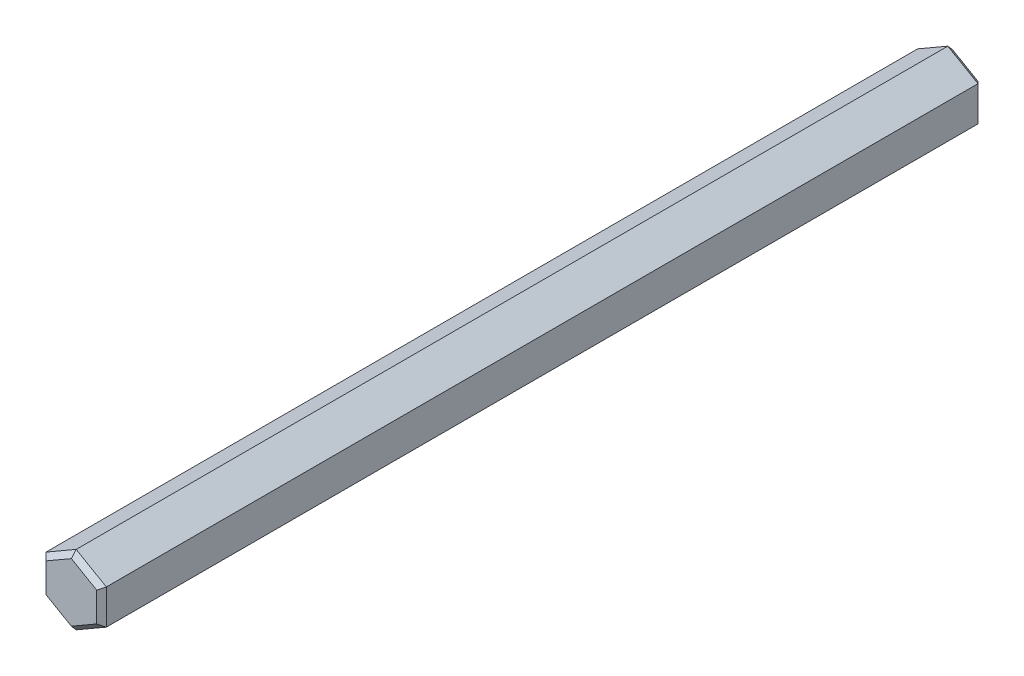
from build123d import *

# Parameters (mm, degrees)
BOSS_EXTRUDE1_DEPTH = 73.025
CHAMFER1_SIZE       = 0.4


with BuildPart() as part:
    # Sketch1 → Boss-Extrude1 (new body)
    with BuildSketch(Plane.XY.offset(75)):
        Polygon((0, -2.886751346), (2.5, -1.443375673), (2.5, 1.443375673), (0, 2.886751346), (-2.5, 1.443375673), (-2.5, -1.443375673), align=None)
    extrude(amount=-BOSS_EXTRUDE1_DEPTH)

    # Chamfer1
    chamfer1_edges = [part.edges().sort_by_distance(p)[0] for p in [
        (2.5, 0, 1.975),
        (1.25, 2.165063509, 1.975),
        (-1.25, 2.165063509, 1.975),
        (-2.5, 0, 1.975),
        (-1.25, -2.165063509, 1.975),
        (-2.5, 0, 75),
        (-1.25, 2.165063509, 75),
        (1.25, 2.165063509, 75),
        (1.25, -2.165063509, 1.975),
        (2.5, 0, 75),
        (1.25, -2.165063509, 75),
        (-1.25, -2.165063509, 75),
    ]]
    chamfer(chamfer1_edges, length=CHAMFER1_SIZE)


solid = part.part
